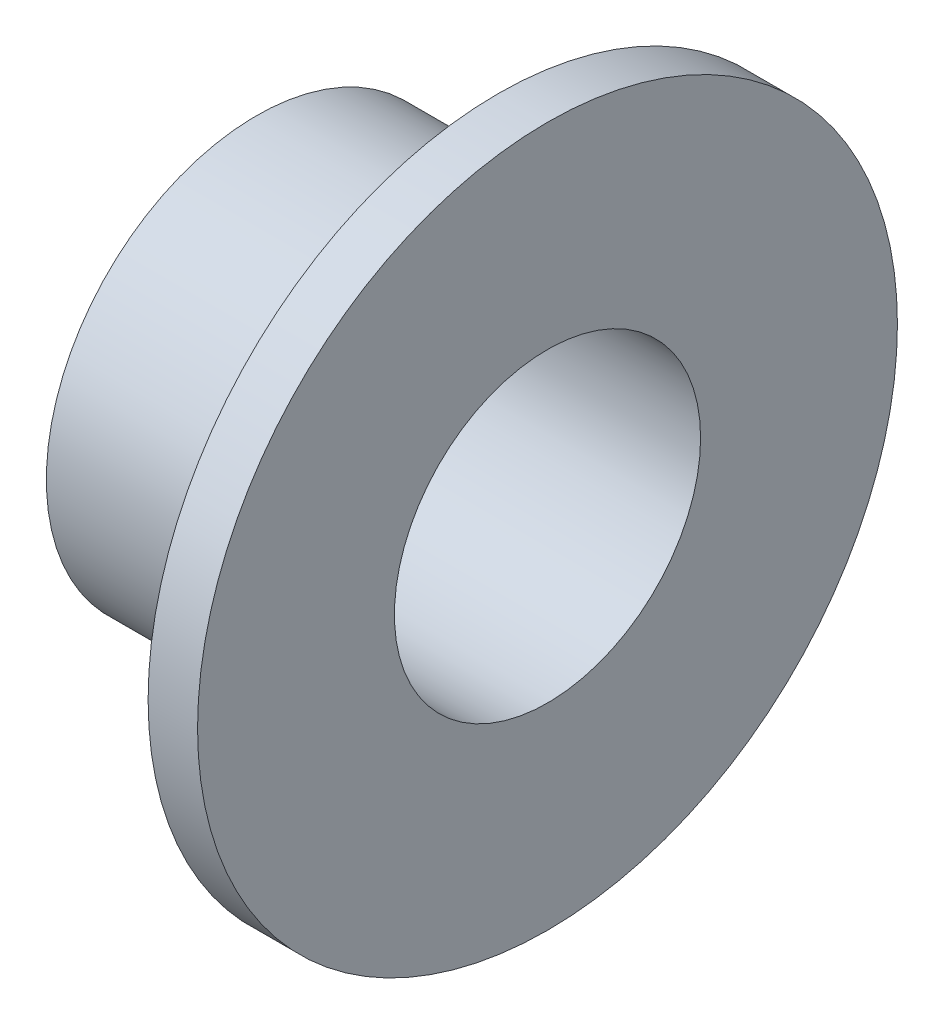
from build123d import *


with BuildPart() as part:
    # Sketch1 → Revolve1 (revolve)
    with BuildSketch(Plane(origin=(0, 0, 0), x_dir=(1, 0, 0), z_dir=(0, 1, 0))):
        Polygon((0, 2.0447), (0, 4.6736), (-0.6604, 4.6736), (-0.6604, 2.8067), (-3.8862, 2.8067), (-3.8862, 2.0447), align=None)
    revolve(axis=Axis((0, 0, 0), (-1, 0, 0)))


solid = part.part
